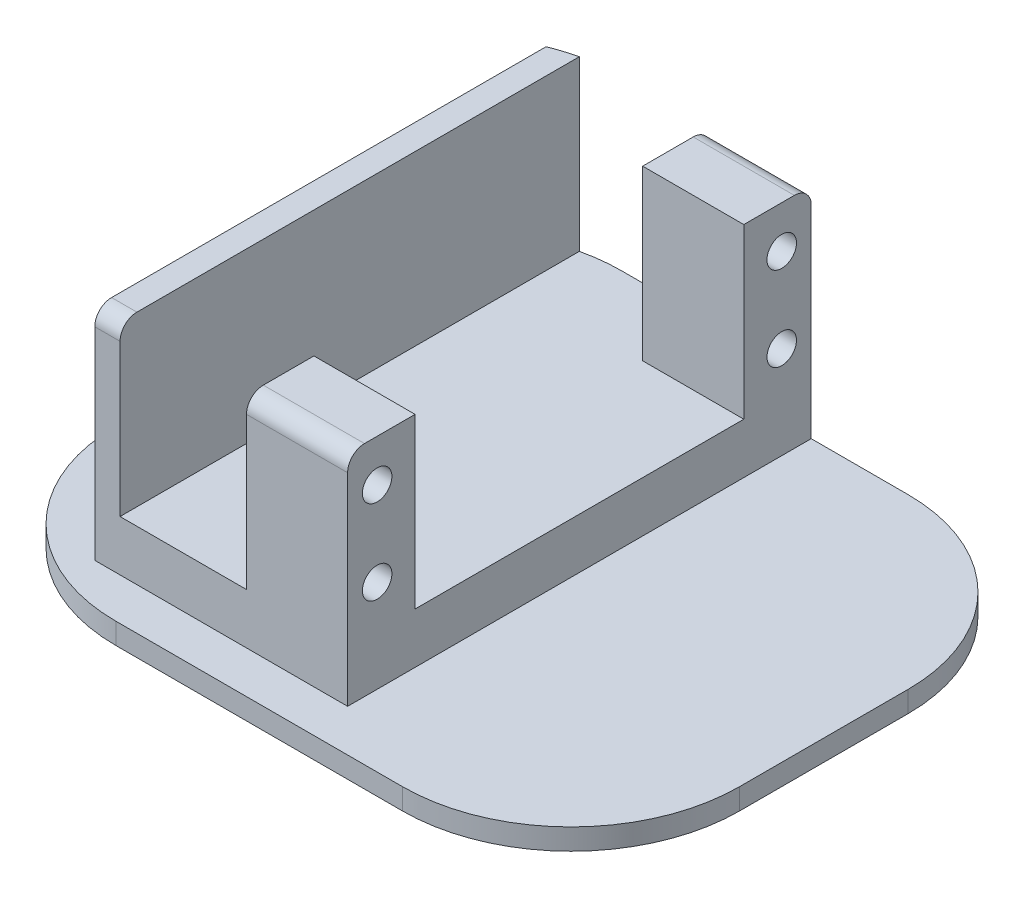
from build123d import *

# Parameters (mm, degrees)
ESQUISSE1_W             = 74
ESQUISSE1_H             = 60
BOSS_EXTRU_1_DEPTH      = 2.5
ESQUISSE2_W             = 30
ESQUISSE2_H             = 55
BOSS_EXTRU_2_DEPTH      = 6
ESQUISSE4_W             = 12
ESQUISSE4_H             = 8
BOSS_EXTRU_3_DEPTH      = 20
ESQUISSE5_R             = 1.75
ENL_V_MAT_EXTRU_1_DEPTH = 20
ESQUISSE6_R             = 2.95
BOSS_EXTRU_4_DEPTH      = 5
CONG_1_R                = 1
CONG_2_R                = 20
CONG_3_R                = 2


with BuildPart() as part:
    # Esquisse1 → Boss.-Extru.1 (new body)
    with BuildSketch(Plane(origin=(0, 0, 0), x_dir=(1, 0, 0), z_dir=(0, 1, 0))):
        with Locations((37, 30)):
            Rectangle(ESQUISSE1_W, ESQUISSE1_H)
    extrude(amount=BOSS_EXTRU_1_DEPTH)

    # Esquisse2 → Boss.-Extru.2 (add)
    with BuildSketch(Plane(origin=(0, 2.5, 0), x_dir=(1, 0, 0), z_dir=(0, 1, 0))):
        with Locations((27.5, 32.5)):
            Rectangle(ESQUISSE2_W, ESQUISSE2_H)
    extrude(amount=BOSS_EXTRU_2_DEPTH)

    # Esquisse4 → Boss.-Extru.3 (add)
    with BuildSketch(Plane(origin=(0, 8.5, 0), x_dir=(1, 0, 0), z_dir=(0, 1, 0))):
        with Locations((36.5, 56)):
            Rectangle(ESQUISSE4_W, ESQUISSE4_H)
        Polygon((12.5, 60), (12.5, 52), (12.5, 13), (12.5, 5), (15.5, 5), (15.5, 13), (15.5, 52), (15.5, 60), align=None)
        with Locations((36.5, 9)):
            Rectangle(ESQUISSE4_W, ESQUISSE4_H)
    extrude(amount=BOSS_EXTRU_3_DEPTH)

    # Esquisse5 → Enlèv. mat.-Extru.1 (cut)
    with BuildSketch(Plane(origin=(42.5, 0, 0), x_dir=(0, 0, -1), z_dir=(1, 0, 0))):
        with Locations((8.5, 23.5)):
            Circle(ESQUISSE5_R)
        with Locations((8.5, 13.5)):
            Circle(ESQUISSE5_R)
        with Locations((56.5, 23.5)):
            Circle(ESQUISSE5_R)
        with Locations((56.5, 13.5)):
            Circle(ESQUISSE5_R)
    extrude(amount=-ENL_V_MAT_EXTRU_1_DEPTH, mode=Mode.SUBTRACT)

    # Esquisse6 → Boss.-Extru.4 (add)
    with BuildSketch(Plane.ZY.offset(-12.5)):
        with Locations((-42, 18.5)):
            Circle(ESQUISSE6_R)
    extrude(amount=BOSS_EXTRU_4_DEPTH)

    # Congé1
    cong_1_edges = [part.edges().sort_by_distance(p)[0] for p in [
        (12.5, 18.5, -44.95),
    ]]
    fillet(cong_1_edges, radius=CONG_1_R)

    # Congé2
    cong_2_edges = [part.edges().sort_by_distance(p)[0] for p in [
        (74, 1.25, -60),
        (74, 1.25, 0),
        (0, 1.25, 0),
        (0, 1.25, -60),
    ]]
    fillet(cong_2_edges, radius=CONG_2_R)

    # Congé3
    cong_3_edges = [part.edges().sort_by_distance(p)[0] for p in [
        (36.5, 28.5, -60),
        (14, 28.5, -5),
        (36.5, 28.5, -5),
    ]]
    fillet(cong_3_edges, radius=CONG_3_R)


solid = part.part
